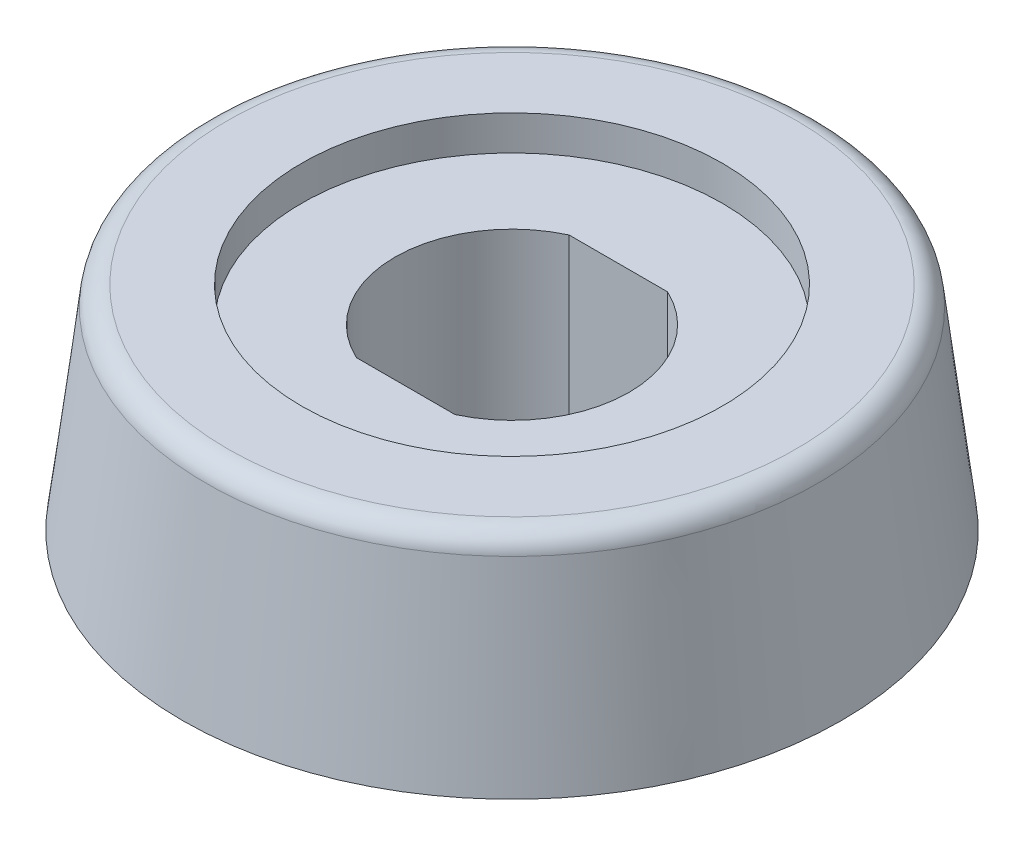
from build123d import *

# Parameters (mm, degrees)
SALIENTE_EXTRUIR1_DEPTH    = 4.9
SALIENTE_EXTRUIR1_TAPER    = 7
CROQUIS2_R                 = 5.8
SALIENTE_EXTRUIR2_DEPTH    = 0.3
CORTAR_EXTRUIR1_DEPTH      = 6.2
CROQUIS4_R                 = 5.8
SALIENTE_EXTRUIR3_DEPTH    = 0.3
CORTAR_EXTRUIR2_DEPTH      = 6.2
CORTAR_EXTRUIR3_DEPTH      = 3.75
CROQUIS7_W                 = 4.85
CROQUIS7_H                 = 0.9
CROQUIS8_W                 = 4.85
CROQUIS8_H                 = 0.9
CROQUIS9_W                 = 3.415
CROQUIS9_H                 = 0.3
CROQUIS10_W                = 3.415
CROQUIS10_H                = 0.3
CROQUIS11_OUTSIDE_W        = 43.344
CROQUIS11_OUTSIDE_H        = 24.694
CROQUIS11_OUTSIDE_R        = 6.99
CORTAR_EXTRUIR8_DEPTH      = 5.9000001
CORTAR_EXTRUIR8_DEPTH_BACK = 1.3
CROQUIS20_R                = 7.6
CROQUIS20_R_2              = 5.8
SALIENTE_EXTRUIR11_DEPTH   = 4.9
SALIENTE_EXTRUIR11_TAPER   = 7
REDONDEO6_R                = 0.5


with BuildPart() as part:
    # Croquis1 → Saliente-Extruir1 (new body)
    with BuildSketch(Plane.XZ):
        with BuildLine():
            Line((-9.325, -7.6), (9.325, -7.6))
            ThreePointArc((9.325, -7.6), (16.925, 0), (9.325, 7.6))
            Line((9.325, 7.6), (-9.325, 7.6))
            ThreePointArc((-9.325, 7.6), (-16.925, 0), (-9.325, -7.6))
        make_face()
    extrude(amount=-SALIENTE_EXTRUIR1_DEPTH, taper=SALIENTE_EXTRUIR1_TAPER)

    # Croquis2 → Saliente-Extruir2 (add)
    with BuildSketch(Plane.XZ):
        with Locations((9.325, 0)):
            Circle(CROQUIS2_R)
    extrude(amount=SALIENTE_EXTRUIR2_DEPTH)

    # Croquis3 → Cortar-Extruir1 (cut, through all)
    with BuildSketch(Plane(origin=(0, 4.9, 0), x_dir=(-1, 0, 0), z_dir=(0, 1, 0))):
        with BuildLine():
            Line((-10.459680572, -2.45), (-8.190319428, -2.45))
            ThreePointArc((-8.190319428, -2.45), (-6.625, 0), (-8.190319428, 2.45))
            Line((-8.190319428, 2.45), (-10.459680572, 2.45))
            ThreePointArc((-10.459680572, 2.45), (-12.025, 0), (-10.459680572, -2.45))
        make_face()
    extrude(amount=-CORTAR_EXTRUIR1_DEPTH, mode=Mode.SUBTRACT)

    # Croquis4 → Saliente-Extruir3 (add)
    with BuildSketch(Plane.XZ):
        with Locations((-9.325, 0)):
            Circle(CROQUIS4_R)
    extrude(amount=SALIENTE_EXTRUIR3_DEPTH)

    # Croquis5 → Cortar-Extruir2 (cut, through all)
    with BuildSketch(Plane(origin=(0, 4.9, 0), x_dir=(-1, 0, 0), z_dir=(0, 1, 0))):
        with BuildLine():
            Line((10.459680572, 2.45), (8.190319428, 2.45))
            ThreePointArc((8.190319428, 2.45), (6.625, 0), (8.190319428, -2.45))
            Line((8.190319428, -2.45), (10.459680572, -2.45))
            ThreePointArc((10.459680572, -2.45), (12.025, 0), (10.459680572, 2.45))
        make_face()
    extrude(amount=-CORTAR_EXTRUIR2_DEPTH, mode=Mode.SUBTRACT)

    # Croquis6 → Cortar-Extruir3 (cut)
    with BuildSketch(Plane.XZ):
        with BuildLine():
            Line((-2.15, 2.8), (-2.15, -2.8))
            ThreePointArc((-2.15, -2.8), (0, -4.95), (2.15, -2.8))
            Line((2.15, -2.8), (2.15, 2.8))
            ThreePointArc((2.15, 2.8), (0, 4.95), (-2.15, 2.8))
        make_face()
    extrude(amount=-CORTAR_EXTRUIR3_DEPTH, mode=Mode.SUBTRACT)

    # Croquis7 → Cortar-Revolución1 (revolve, cut)
    with BuildSketch(Plane(origin=(-9.325, 0, 0), x_dir=(0, 0, -1), z_dir=(1, 0, 0))):
        with Locations((2.425, 4.55)):
            Rectangle(CROQUIS7_W, CROQUIS7_H)
    revolve(axis=Axis((-9.325, 5, 0), (0, -1, 0)), mode=Mode.SUBTRACT)

    # Croquis8 → Cortar-Revolución2 (revolve, cut)
    with BuildSketch(Plane(origin=(9.325, 0, 0), x_dir=(0, 0, -1), z_dir=(1, 0, 0))):
        with Locations((2.425, 4.55)):
            Rectangle(CROQUIS8_W, CROQUIS8_H)
    revolve(axis=Axis((9.325, 5, 0), (0, -1, 0)), mode=Mode.SUBTRACT)

    # Croquis9 → Cortar-Revolución3 (revolve, cut)
    with BuildSketch(Plane(origin=(-9.325, 0, 0), x_dir=(0, 0, -1), z_dir=(1, 0, 0))):
        with Locations((1.7075, -0.15)):
            Rectangle(CROQUIS9_W, CROQUIS9_H)
    revolve(axis=Axis((-9.325, 0, 0), (0, -1, 0)), mode=Mode.SUBTRACT)

    # Croquis10 → Cortar-Revolución4 (revolve, cut)
    with BuildSketch(Plane(origin=(9.325, 0, 0), x_dir=(0, 0, -1), z_dir=(1, 0, 0))):
        with Locations((1.7075, -0.15)):
            Rectangle(CROQUIS10_W, CROQUIS10_H)
    revolve(axis=Axis((9.325, 0, 0), (0, -1, 0)), mode=Mode.SUBTRACT)

    # Croquis11 outside → Cortar-Extruir8 (cut, two sides)
    with BuildSketch(Plane(origin=(0, 0, 0), x_dir=(1, 0, 0), z_dir=(0, 1, 0))) as cortar_extruir8_sk:
        Rectangle(CROQUIS11_OUTSIDE_W, CROQUIS11_OUTSIDE_H)
        with Locations((-9.325, 0)):
            Circle(CROQUIS11_OUTSIDE_R, mode=Mode.SUBTRACT)
    extrude(amount=CORTAR_EXTRUIR8_DEPTH, mode=Mode.SUBTRACT)
    extrude(cortar_extruir8_sk.sketch, amount=-CORTAR_EXTRUIR8_DEPTH_BACK, mode=Mode.SUBTRACT)

    # Croquis20 → Saliente-Extruir11 (add)
    with BuildSketch(Plane.XZ):
        with Locations((-9.325, 0)):
            Circle(CROQUIS20_R)
        with Locations((-9.325, 0)):
            Circle(CROQUIS20_R_2, mode=Mode.SUBTRACT)
    extrude(amount=-SALIENTE_EXTRUIR11_DEPTH, taper=SALIENTE_EXTRUIR11_TAPER)

    # Redondeo6
    redondeo6_edges = [part.edges().sort_by_distance(p)[0] for p in [
        (-16.323355652, 4.9, 0),
    ]]
    fillet(redondeo6_edges, radius=REDONDEO6_R)


solid = part.part
